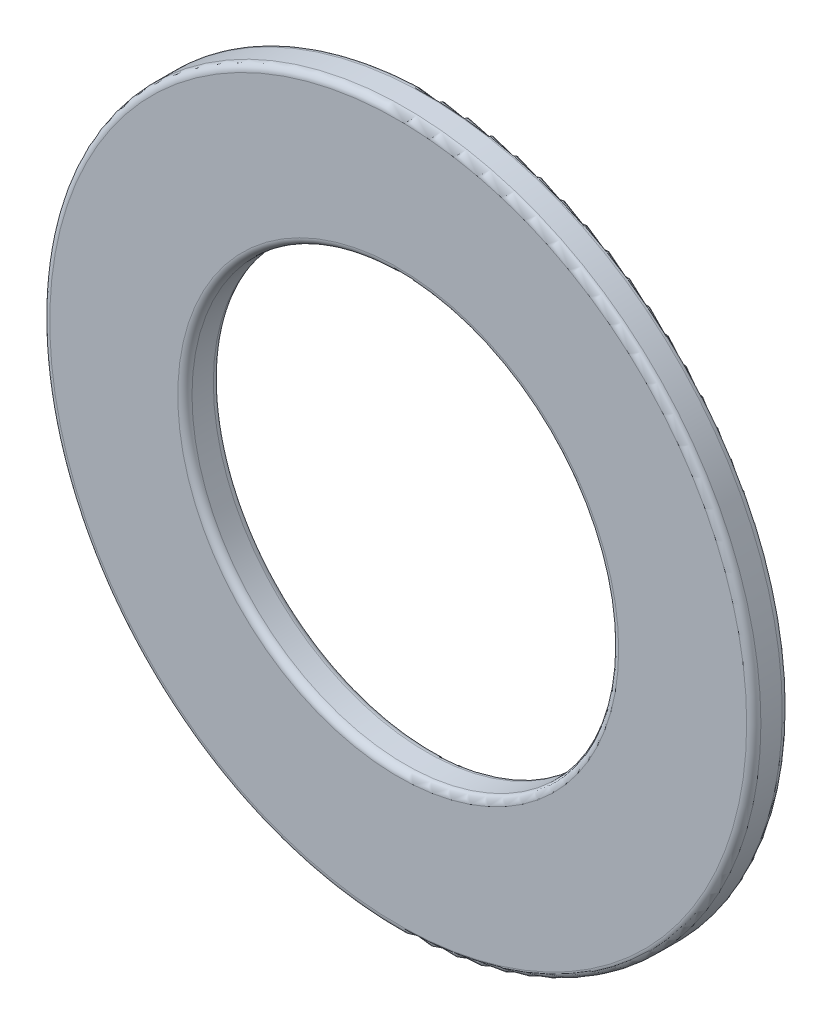
from build123d import *

# Parameters (mm, degrees)
SCHIZZO1_R                   = 5
SCHIZZO1_R_2                 = 3
ESTRUSIONE_ESTRUSIONE1_DEPTH = 0.5
RACCORDO1_R                  = 0.1


with BuildPart() as part:
    # Schizzo1 → Estrusione-Estrusione1 (new body)
    with BuildSketch(Plane.XY):
        Circle(SCHIZZO1_R)
        Circle(SCHIZZO1_R_2, mode=Mode.SUBTRACT)
    extrude(amount=ESTRUSIONE_ESTRUSIONE1_DEPTH)

    # Raccordo1
    raccordo1_edges = [part.edges().sort_by_distance(p)[0] for p in [
        (-5, 0, 0),
        (-5, 0, 0.5),
        (-3, 0, 0),
        (-3, 0, 0.5),
    ]]
    fillet(raccordo1_edges, radius=RACCORDO1_R)


solid = part.part
